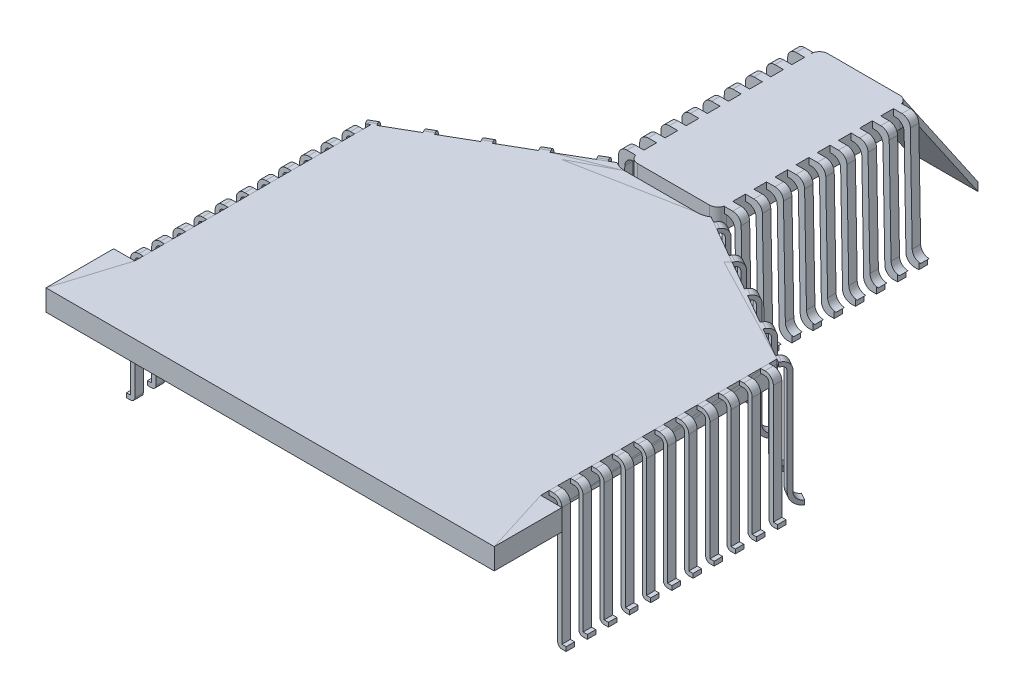
from build123d import *

# Parameters (mm, degrees)
SKETCH1_W             = 21
SKETCH1_H             = 45
BOSS_EXTRUDE1_DEPTH   = 5
FILLET1_R             = 2
BOSS_EXTRUDE2_DEPTH   = 1
LPATTERN1_COUNT       = 5
LPATTERN1_PITCH       = 5
LPATTERN1_COUNT_DIR2  = 5
LPATTERN1_PITCH_DIR2  = 5
MIRROR1_COPY_1_DEPTH  = 1
MIRROR1_COPY_2_DEPTH  = 1
MIRROR1_COPY_3_DEPTH  = 1
MIRROR1_COPY_4_DEPTH  = 1
MIRROR1_COPY_5_DEPTH  = 1
MIRROR1_COPY_6_DEPTH  = 1
MIRROR1_COPY_7_DEPTH  = 1
MIRROR1_COPY_8_DEPTH  = 1
MIRROR1_COPY_9_DEPTH  = 1
MIRROR1_COPY_10_DEPTH = 1
MIRROR1_COPY_11_DEPTH = 1
MIRROR1_COPY_12_DEPTH = 1
MIRROR1_COPY_13_DEPTH = 1
MIRROR1_COPY_14_DEPTH = 1
MIRROR1_COPY_15_DEPTH = 1
MIRROR1_COPY_16_DEPTH = 1
MIRROR1_COPY_17_DEPTH = 1
MIRROR1_COPY_18_DEPTH = 1
MIRROR1_COPY_19_DEPTH = 1
MIRROR1_COPY_20_DEPTH = 1
MIRROR1_COPY_21_DEPTH = 1
MIRROR1_COPY_22_DEPTH = 1
MIRROR1_COPY_23_DEPTH = 1
MIRROR1_COPY_24_DEPTH = 1
SKETCH4_W             = 17
SKETCH4_H             = 2
BOSS_EXTRUDE4_DEPTH   = 5
BOSS_EXTRUDE5_DEPTH   = 1
LPATTERN2_COUNT       = 5
LPATTERN2_PITCH       = 10
BOSS_EXTRUDE7_START   = 2
BOSS_EXTRUDE7_DEPTH   = 2
LPATTERN3_COUNT       = 11
LPATTERN3_PITCH       = 5


with BuildPart() as part:
    # Sketch1 → Boss-Extrude1 (new body)
    with BuildSketch(Plane(origin=(0, 0, 0), x_dir=(1, 0, 0), z_dir=(0, 1, 0))):
        Rectangle(SKETCH1_W, SKETCH1_H)
    extrude(amount=BOSS_EXTRUDE1_DEPTH)

    # Fillet1
    fillet1_edges = [part.edges().sort_by_distance(p)[0] for p in [
        (-10.5, 2.5, -22.5),
        (-10.5, 2.5, 22.5),
        (10.5, 2.5, -22.5),
        (10.5, 2.5, 22.5),
    ]]
    fillet(fillet1_edges, radius=FILLET1_R)

    # Sketch2 → Boss-Extrude2 (add, symmetric)
    with BuildSketch(Plane.XY):
        with BuildLine():
            Line((10.5, 3.5), (11.026542382, 3.5))
            ThreePointArc((11.026542382, 3.5), (12.428076219, 2.926780608), (13.026223683, 1.535702904))
            Line((13.026223683, 1.535702904), (13.464928856, -23.035702904))
            ThreePointArc((13.464928856, -23.035702904), (14.06307632, -24.426780608), (15.464610157, -25))
            Line((15.464610157, -25), (16.5, -25))
            Line((16.5, -25), (16.5, -23.5))
            Line((16.5, -23.5), (16.938067774, -23.5))
            ThreePointArc((16.938067774, -23.5), (15.536533937, -22.926780608), (14.938386474, -21.535702904))
            Line((14.938386474, -21.535702904), (14.4996813, 3.035702904))
            ThreePointArc((14.4996813, 3.035702904), (13.901533837, 4.426780608), (12.5, 5))
            Line((12.5, 5), (10.5, 5))
            Line((10.5, 5), (10.5, 3.5))
        make_face()
    boss_extrude2 = extrude(amount=BOSS_EXTRUDE2_DEPTH, both=True)

    # LPattern1: Boss-Extrude2 5 × 5
    with Locations(*[Vector(0, 0, -1) * (i * LPATTERN1_PITCH) + Vector(0, 0, 1) * (j * LPATTERN1_PITCH_DIR2) for i in range(LPATTERN1_COUNT) for j in range(LPATTERN1_COUNT_DIR2) if (i, j) != (0, 0)]):
        add(boss_extrude2)

    # Mirror1: Boss-Extrude2 across plane
    add(boss_extrude2.mirror(Plane(origin=(0, 0, 0), x_dir=(0, 0, 1), z_dir=(1, 0, 0))))

    # Mirror1 copy 1 sketch → Mirror1 copy 1 (add, symmetric)
    with BuildSketch(Plane(origin=(0, 0, 5), x_dir=(-1, 0, 0), z_dir=(0, 0, 1))):
        with BuildLine():
            Line((10.5, -3.5), (11.026542382, -3.5))
            ThreePointArc((11.026542382, -3.5), (12.428076219, -2.926780608), (13.026223683, -1.535702904))
            Line((13.026223683, -1.535702904), (13.464928856, 23.035702904))
            ThreePointArc((13.464928856, 23.035702904), (14.06307632, 24.426780608), (15.464610157, 25))
            Line((15.464610157, 25), (16.5, 25))
            Line((16.5, 25), (16.5, 23.5))
            Line((16.5, 23.5), (16.938067774, 23.5))
            ThreePointArc((16.938067774, 23.5), (15.536533937, 22.926780608), (14.938386474, 21.535702904))
            Line((14.938386474, 21.535702904), (14.4996813, -3.035702904))
            ThreePointArc((14.4996813, -3.035702904), (13.901533837, -4.426780608), (12.5, -5))
            Line((12.5, -5), (10.5, -5))
            Line((10.5, -5), (10.5, -3.5))
        make_face()
    extrude(amount=MIRROR1_COPY_1_DEPTH, both=True)

    # Mirror1 copy 2 sketch → Mirror1 copy 2 (add, symmetric)
    with BuildSketch(Plane(origin=(0, 0, 10), x_dir=(-1, 0, 0), z_dir=(0, 0, 1))):
        with BuildLine():
            Line((10.5, -3.5), (11.026542382, -3.5))
            ThreePointArc((11.026542382, -3.5), (12.428076219, -2.926780608), (13.026223683, -1.535702904))
            Line((13.026223683, -1.535702904), (13.464928856, 23.035702904))
            ThreePointArc((13.464928856, 23.035702904), (14.06307632, 24.426780608), (15.464610157, 25))
            Line((15.464610157, 25), (16.5, 25))
            Line((16.5, 25), (16.5, 23.5))
            Line((16.5, 23.5), (16.938067774, 23.5))
            ThreePointArc((16.938067774, 23.5), (15.536533937, 22.926780608), (14.938386474, 21.535702904))
            Line((14.938386474, 21.535702904), (14.4996813, -3.035702904))
            ThreePointArc((14.4996813, -3.035702904), (13.901533837, -4.426780608), (12.5, -5))
            Line((12.5, -5), (10.5, -5))
            Line((10.5, -5), (10.5, -3.5))
        make_face()
    extrude(amount=MIRROR1_COPY_2_DEPTH, both=True)

    # Mirror1 copy 3 sketch → Mirror1 copy 3 (add, symmetric)
    with BuildSketch(Plane(origin=(0, 0, 15), x_dir=(-1, 0, 0), z_dir=(0, 0, 1))):
        with BuildLine():
            Line((10.5, -3.5), (11.026542382, -3.5))
            ThreePointArc((11.026542382, -3.5), (12.428076219, -2.926780608), (13.026223683, -1.535702904))
            Line((13.026223683, -1.535702904), (13.464928856, 23.035702904))
            ThreePointArc((13.464928856, 23.035702904), (14.06307632, 24.426780608), (15.464610157, 25))
            Line((15.464610157, 25), (16.5, 25))
            Line((16.5, 25), (16.5, 23.5))
            Line((16.5, 23.5), (16.938067774, 23.5))
            ThreePointArc((16.938067774, 23.5), (15.536533937, 22.926780608), (14.938386474, 21.535702904))
            Line((14.938386474, 21.535702904), (14.4996813, -3.035702904))
            ThreePointArc((14.4996813, -3.035702904), (13.901533837, -4.426780608), (12.5, -5))
            Line((12.5, -5), (10.5, -5))
            Line((10.5, -5), (10.5, -3.5))
        make_face()
    extrude(amount=MIRROR1_COPY_3_DEPTH, both=True)

    # Mirror1 copy 4 sketch → Mirror1 copy 4 (add, symmetric)
    with BuildSketch(Plane(origin=(0, 0, 20), x_dir=(-1, 0, 0), z_dir=(0, 0, 1))):
        with BuildLine():
            Line((10.5, -3.5), (11.026542382, -3.5))
            ThreePointArc((11.026542382, -3.5), (12.428076219, -2.926780608), (13.026223683, -1.535702904))
            Line((13.026223683, -1.535702904), (13.464928856, 23.035702904))
            ThreePointArc((13.464928856, 23.035702904), (14.06307632, 24.426780608), (15.464610157, 25))
            Line((15.464610157, 25), (16.5, 25))
            Line((16.5, 25), (16.5, 23.5))
            Line((16.5, 23.5), (16.938067774, 23.5))
            ThreePointArc((16.938067774, 23.5), (15.536533937, 22.926780608), (14.938386474, 21.535702904))
            Line((14.938386474, 21.535702904), (14.4996813, -3.035702904))
            ThreePointArc((14.4996813, -3.035702904), (13.901533837, -4.426780608), (12.5, -5))
            Line((12.5, -5), (10.5, -5))
            Line((10.5, -5), (10.5, -3.5))
        make_face()
    extrude(amount=MIRROR1_COPY_4_DEPTH, both=True)

    # Mirror1 copy 5 sketch → Mirror1 copy 5 (add, symmetric)
    with BuildSketch(Plane(origin=(0, 0, -5), x_dir=(-1, 0, 0), z_dir=(0, 0, 1))):
        with BuildLine():
            Line((10.5, -3.5), (11.026542382, -3.5))
            ThreePointArc((11.026542382, -3.5), (12.428076219, -2.926780608), (13.026223683, -1.535702904))
            Line((13.026223683, -1.535702904), (13.464928856, 23.035702904))
            ThreePointArc((13.464928856, 23.035702904), (14.06307632, 24.426780608), (15.464610157, 25))
            Line((15.464610157, 25), (16.5, 25))
            Line((16.5, 25), (16.5, 23.5))
            Line((16.5, 23.5), (16.938067774, 23.5))
            ThreePointArc((16.938067774, 23.5), (15.536533937, 22.926780608), (14.938386474, 21.535702904))
            Line((14.938386474, 21.535702904), (14.4996813, -3.035702904))
            ThreePointArc((14.4996813, -3.035702904), (13.901533837, -4.426780608), (12.5, -5))
            Line((12.5, -5), (10.5, -5))
            Line((10.5, -5), (10.5, -3.5))
        make_face()
    extrude(amount=MIRROR1_COPY_5_DEPTH, both=True)

    # Mirror1 copy 6 sketch → Mirror1 copy 6 (add, symmetric)
    with BuildSketch(Plane(origin=(0, 0, 0), x_dir=(-1, 0, 0), z_dir=(0, 0, 1))):
        with BuildLine():
            Line((10.5, -3.5), (11.026542382, -3.5))
            ThreePointArc((11.026542382, -3.5), (12.428076219, -2.926780608), (13.026223683, -1.535702904))
            Line((13.026223683, -1.535702904), (13.464928856, 23.035702904))
            ThreePointArc((13.464928856, 23.035702904), (14.06307632, 24.426780608), (15.464610157, 25))
            Line((15.464610157, 25), (16.5, 25))
            Line((16.5, 25), (16.5, 23.5))
            Line((16.5, 23.5), (16.938067774, 23.5))
            ThreePointArc((16.938067774, 23.5), (15.536533937, 22.926780608), (14.938386474, 21.535702904))
            Line((14.938386474, 21.535702904), (14.4996813, -3.035702904))
            ThreePointArc((14.4996813, -3.035702904), (13.901533837, -4.426780608), (12.5, -5))
            Line((12.5, -5), (10.5, -5))
            Line((10.5, -5), (10.5, -3.5))
        make_face()
    extrude(amount=MIRROR1_COPY_6_DEPTH, both=True)

    # Mirror1 copy 7 sketch → Mirror1 copy 7 (add, symmetric)
    with BuildSketch(Plane(origin=(0, 0, 5), x_dir=(-1, 0, 0), z_dir=(0, 0, 1))):
        with BuildLine():
            Line((10.5, -3.5), (11.026542382, -3.5))
            ThreePointArc((11.026542382, -3.5), (12.428076219, -2.926780608), (13.026223683, -1.535702904))
            Line((13.026223683, -1.535702904), (13.464928856, 23.035702904))
            ThreePointArc((13.464928856, 23.035702904), (14.06307632, 24.426780608), (15.464610157, 25))
            Line((15.464610157, 25), (16.5, 25))
            Line((16.5, 25), (16.5, 23.5))
            Line((16.5, 23.5), (16.938067774, 23.5))
            ThreePointArc((16.938067774, 23.5), (15.536533937, 22.926780608), (14.938386474, 21.535702904))
            Line((14.938386474, 21.535702904), (14.4996813, -3.035702904))
            ThreePointArc((14.4996813, -3.035702904), (13.901533837, -4.426780608), (12.5, -5))
            Line((12.5, -5), (10.5, -5))
            Line((10.5, -5), (10.5, -3.5))
        make_face()
    extrude(amount=MIRROR1_COPY_7_DEPTH, both=True)

    # Mirror1 copy 8 sketch → Mirror1 copy 8 (add, symmetric)
    with BuildSketch(Plane(origin=(0, 0, 10), x_dir=(-1, 0, 0), z_dir=(0, 0, 1))):
        with BuildLine():
            Line((10.5, -3.5), (11.026542382, -3.5))
            ThreePointArc((11.026542382, -3.5), (12.428076219, -2.926780608), (13.026223683, -1.535702904))
            Line((13.026223683, -1.535702904), (13.464928856, 23.035702904))
            ThreePointArc((13.464928856, 23.035702904), (14.06307632, 24.426780608), (15.464610157, 25))
            Line((15.464610157, 25), (16.5, 25))
            Line((16.5, 25), (16.5, 23.5))
            Line((16.5, 23.5), (16.938067774, 23.5))
            ThreePointArc((16.938067774, 23.5), (15.536533937, 22.926780608), (14.938386474, 21.535702904))
            Line((14.938386474, 21.535702904), (14.4996813, -3.035702904))
            ThreePointArc((14.4996813, -3.035702904), (13.901533837, -4.426780608), (12.5, -5))
            Line((12.5, -5), (10.5, -5))
            Line((10.5, -5), (10.5, -3.5))
        make_face()
    extrude(amount=MIRROR1_COPY_8_DEPTH, both=True)

    # Mirror1 copy 9 sketch → Mirror1 copy 9 (add, symmetric)
    with BuildSketch(Plane(origin=(0, 0, 15), x_dir=(-1, 0, 0), z_dir=(0, 0, 1))):
        with BuildLine():
            Line((10.5, -3.5), (11.026542382, -3.5))
            ThreePointArc((11.026542382, -3.5), (12.428076219, -2.926780608), (13.026223683, -1.535702904))
            Line((13.026223683, -1.535702904), (13.464928856, 23.035702904))
            ThreePointArc((13.464928856, 23.035702904), (14.06307632, 24.426780608), (15.464610157, 25))
            Line((15.464610157, 25), (16.5, 25))
            Line((16.5, 25), (16.5, 23.5))
            Line((16.5, 23.5), (16.938067774, 23.5))
            ThreePointArc((16.938067774, 23.5), (15.536533937, 22.926780608), (14.938386474, 21.535702904))
            Line((14.938386474, 21.535702904), (14.4996813, -3.035702904))
            ThreePointArc((14.4996813, -3.035702904), (13.901533837, -4.426780608), (12.5, -5))
            Line((12.5, -5), (10.5, -5))
            Line((10.5, -5), (10.5, -3.5))
        make_face()
    extrude(amount=MIRROR1_COPY_9_DEPTH, both=True)

    # Mirror1 copy 10 sketch → Mirror1 copy 10 (add, symmetric)
    with BuildSketch(Plane(origin=(0, 0, -10), x_dir=(-1, 0, 0), z_dir=(0, 0, 1))):
        with BuildLine():
            Line((10.5, -3.5), (11.026542382, -3.5))
            ThreePointArc((11.026542382, -3.5), (12.428076219, -2.926780608), (13.026223683, -1.535702904))
            Line((13.026223683, -1.535702904), (13.464928856, 23.035702904))
            ThreePointArc((13.464928856, 23.035702904), (14.06307632, 24.426780608), (15.464610157, 25))
            Line((15.464610157, 25), (16.5, 25))
            Line((16.5, 25), (16.5, 23.5))
            Line((16.5, 23.5), (16.938067774, 23.5))
            ThreePointArc((16.938067774, 23.5), (15.536533937, 22.926780608), (14.938386474, 21.535702904))
            Line((14.938386474, 21.535702904), (14.4996813, -3.035702904))
            ThreePointArc((14.4996813, -3.035702904), (13.901533837, -4.426780608), (12.5, -5))
            Line((12.5, -5), (10.5, -5))
            Line((10.5, -5), (10.5, -3.5))
        make_face()
    extrude(amount=MIRROR1_COPY_10_DEPTH, both=True)

    # Mirror1 copy 11 sketch → Mirror1 copy 11 (add, symmetric)
    with BuildSketch(Plane(origin=(0, 0, -5), x_dir=(-1, 0, 0), z_dir=(0, 0, 1))):
        with BuildLine():
            Line((10.5, -3.5), (11.026542382, -3.5))
            ThreePointArc((11.026542382, -3.5), (12.428076219, -2.926780608), (13.026223683, -1.535702904))
            Line((13.026223683, -1.535702904), (13.464928856, 23.035702904))
            ThreePointArc((13.464928856, 23.035702904), (14.06307632, 24.426780608), (15.464610157, 25))
            Line((15.464610157, 25), (16.5, 25))
            Line((16.5, 25), (16.5, 23.5))
            Line((16.5, 23.5), (16.938067774, 23.5))
            ThreePointArc((16.938067774, 23.5), (15.536533937, 22.926780608), (14.938386474, 21.535702904))
            Line((14.938386474, 21.535702904), (14.4996813, -3.035702904))
            ThreePointArc((14.4996813, -3.035702904), (13.901533837, -4.426780608), (12.5, -5))
            Line((12.5, -5), (10.5, -5))
            Line((10.5, -5), (10.5, -3.5))
        make_face()
    extrude(amount=MIRROR1_COPY_11_DEPTH, both=True)

    # Mirror1 copy 12 sketch → Mirror1 copy 12 (add, symmetric)
    with BuildSketch(Plane(origin=(0, 0, 0), x_dir=(-1, 0, 0), z_dir=(0, 0, 1))):
        with BuildLine():
            Line((10.5, -3.5), (11.026542382, -3.5))
            ThreePointArc((11.026542382, -3.5), (12.428076219, -2.926780608), (13.026223683, -1.535702904))
            Line((13.026223683, -1.535702904), (13.464928856, 23.035702904))
            ThreePointArc((13.464928856, 23.035702904), (14.06307632, 24.426780608), (15.464610157, 25))
            Line((15.464610157, 25), (16.5, 25))
            Line((16.5, 25), (16.5, 23.5))
            Line((16.5, 23.5), (16.938067774, 23.5))
            ThreePointArc((16.938067774, 23.5), (15.536533937, 22.926780608), (14.938386474, 21.535702904))
            Line((14.938386474, 21.535702904), (14.4996813, -3.035702904))
            ThreePointArc((14.4996813, -3.035702904), (13.901533837, -4.426780608), (12.5, -5))
            Line((12.5, -5), (10.5, -5))
            Line((10.5, -5), (10.5, -3.5))
        make_face()
    extrude(amount=MIRROR1_COPY_12_DEPTH, both=True)

    # Mirror1 copy 13 sketch → Mirror1 copy 13 (add, symmetric)
    with BuildSketch(Plane(origin=(0, 0, 5), x_dir=(-1, 0, 0), z_dir=(0, 0, 1))):
        with BuildLine():
            Line((10.5, -3.5), (11.026542382, -3.5))
            ThreePointArc((11.026542382, -3.5), (12.428076219, -2.926780608), (13.026223683, -1.535702904))
            Line((13.026223683, -1.535702904), (13.464928856, 23.035702904))
            ThreePointArc((13.464928856, 23.035702904), (14.06307632, 24.426780608), (15.464610157, 25))
            Line((15.464610157, 25), (16.5, 25))
            Line((16.5, 25), (16.5, 23.5))
            Line((16.5, 23.5), (16.938067774, 23.5))
            ThreePointArc((16.938067774, 23.5), (15.536533937, 22.926780608), (14.938386474, 21.535702904))
            Line((14.938386474, 21.535702904), (14.4996813, -3.035702904))
            ThreePointArc((14.4996813, -3.035702904), (13.901533837, -4.426780608), (12.5, -5))
            Line((12.5, -5), (10.5, -5))
            Line((10.5, -5), (10.5, -3.5))
        make_face()
    extrude(amount=MIRROR1_COPY_13_DEPTH, both=True)

    # Mirror1 copy 14 sketch → Mirror1 copy 14 (add, symmetric)
    with BuildSketch(Plane(origin=(0, 0, 10), x_dir=(-1, 0, 0), z_dir=(0, 0, 1))):
        with BuildLine():
            Line((10.5, -3.5), (11.026542382, -3.5))
            ThreePointArc((11.026542382, -3.5), (12.428076219, -2.926780608), (13.026223683, -1.535702904))
            Line((13.026223683, -1.535702904), (13.464928856, 23.035702904))
            ThreePointArc((13.464928856, 23.035702904), (14.06307632, 24.426780608), (15.464610157, 25))
            Line((15.464610157, 25), (16.5, 25))
            Line((16.5, 25), (16.5, 23.5))
            Line((16.5, 23.5), (16.938067774, 23.5))
            ThreePointArc((16.938067774, 23.5), (15.536533937, 22.926780608), (14.938386474, 21.535702904))
            Line((14.938386474, 21.535702904), (14.4996813, -3.035702904))
            ThreePointArc((14.4996813, -3.035702904), (13.901533837, -4.426780608), (12.5, -5))
            Line((12.5, -5), (10.5, -5))
            Line((10.5, -5), (10.5, -3.5))
        make_face()
    extrude(amount=MIRROR1_COPY_14_DEPTH, both=True)

    # Mirror1 copy 15 sketch → Mirror1 copy 15 (add, symmetric)
    with BuildSketch(Plane(origin=(0, 0, -15), x_dir=(-1, 0, 0), z_dir=(0, 0, 1))):
        with BuildLine():
            Line((10.5, -3.5), (11.026542382, -3.5))
            ThreePointArc((11.026542382, -3.5), (12.428076219, -2.926780608), (13.026223683, -1.535702904))
            Line((13.026223683, -1.535702904), (13.464928856, 23.035702904))
            ThreePointArc((13.464928856, 23.035702904), (14.06307632, 24.426780608), (15.464610157, 25))
            Line((15.464610157, 25), (16.5, 25))
            Line((16.5, 25), (16.5, 23.5))
            Line((16.5, 23.5), (16.938067774, 23.5))
            ThreePointArc((16.938067774, 23.5), (15.536533937, 22.926780608), (14.938386474, 21.535702904))
            Line((14.938386474, 21.535702904), (14.4996813, -3.035702904))
            ThreePointArc((14.4996813, -3.035702904), (13.901533837, -4.426780608), (12.5, -5))
            Line((12.5, -5), (10.5, -5))
            Line((10.5, -5), (10.5, -3.5))
        make_face()
    extrude(amount=MIRROR1_COPY_15_DEPTH, both=True)

    # Mirror1 copy 16 sketch → Mirror1 copy 16 (add, symmetric)
    with BuildSketch(Plane(origin=(0, 0, -10), x_dir=(-1, 0, 0), z_dir=(0, 0, 1))):
        with BuildLine():
            Line((10.5, -3.5), (11.026542382, -3.5))
            ThreePointArc((11.026542382, -3.5), (12.428076219, -2.926780608), (13.026223683, -1.535702904))
            Line((13.026223683, -1.535702904), (13.464928856, 23.035702904))
            ThreePointArc((13.464928856, 23.035702904), (14.06307632, 24.426780608), (15.464610157, 25))
            Line((15.464610157, 25), (16.5, 25))
            Line((16.5, 25), (16.5, 23.5))
            Line((16.5, 23.5), (16.938067774, 23.5))
            ThreePointArc((16.938067774, 23.5), (15.536533937, 22.926780608), (14.938386474, 21.535702904))
            Line((14.938386474, 21.535702904), (14.4996813, -3.035702904))
            ThreePointArc((14.4996813, -3.035702904), (13.901533837, -4.426780608), (12.5, -5))
            Line((12.5, -5), (10.5, -5))
            Line((10.5, -5), (10.5, -3.5))
        make_face()
    extrude(amount=MIRROR1_COPY_16_DEPTH, both=True)

    # Mirror1 copy 17 sketch → Mirror1 copy 17 (add, symmetric)
    with BuildSketch(Plane(origin=(0, 0, -5), x_dir=(-1, 0, 0), z_dir=(0, 0, 1))):
        with BuildLine():
            Line((10.5, -3.5), (11.026542382, -3.5))
            ThreePointArc((11.026542382, -3.5), (12.428076219, -2.926780608), (13.026223683, -1.535702904))
            Line((13.026223683, -1.535702904), (13.464928856, 23.035702904))
            ThreePointArc((13.464928856, 23.035702904), (14.06307632, 24.426780608), (15.464610157, 25))
            Line((15.464610157, 25), (16.5, 25))
            Line((16.5, 25), (16.5, 23.5))
            Line((16.5, 23.5), (16.938067774, 23.5))
            ThreePointArc((16.938067774, 23.5), (15.536533937, 22.926780608), (14.938386474, 21.535702904))
            Line((14.938386474, 21.535702904), (14.4996813, -3.035702904))
            ThreePointArc((14.4996813, -3.035702904), (13.901533837, -4.426780608), (12.5, -5))
            Line((12.5, -5), (10.5, -5))
            Line((10.5, -5), (10.5, -3.5))
        make_face()
    extrude(amount=MIRROR1_COPY_17_DEPTH, both=True)

    # Mirror1 copy 18 sketch → Mirror1 copy 18 (add, symmetric)
    with BuildSketch(Plane(origin=(0, 0, 0), x_dir=(-1, 0, 0), z_dir=(0, 0, 1))):
        with BuildLine():
            Line((10.5, -3.5), (11.026542382, -3.5))
            ThreePointArc((11.026542382, -3.5), (12.428076219, -2.926780608), (13.026223683, -1.535702904))
            Line((13.026223683, -1.535702904), (13.464928856, 23.035702904))
            ThreePointArc((13.464928856, 23.035702904), (14.06307632, 24.426780608), (15.464610157, 25))
            Line((15.464610157, 25), (16.5, 25))
            Line((16.5, 25), (16.5, 23.5))
            Line((16.5, 23.5), (16.938067774, 23.5))
            ThreePointArc((16.938067774, 23.5), (15.536533937, 22.926780608), (14.938386474, 21.535702904))
            Line((14.938386474, 21.535702904), (14.4996813, -3.035702904))
            ThreePointArc((14.4996813, -3.035702904), (13.901533837, -4.426780608), (12.5, -5))
            Line((12.5, -5), (10.5, -5))
            Line((10.5, -5), (10.5, -3.5))
        make_face()
    extrude(amount=MIRROR1_COPY_18_DEPTH, both=True)

    # Mirror1 copy 19 sketch → Mirror1 copy 19 (add, symmetric)
    with BuildSketch(Plane(origin=(0, 0, 5), x_dir=(-1, 0, 0), z_dir=(0, 0, 1))):
        with BuildLine():
            Line((10.5, -3.5), (11.026542382, -3.5))
            ThreePointArc((11.026542382, -3.5), (12.428076219, -2.926780608), (13.026223683, -1.535702904))
            Line((13.026223683, -1.535702904), (13.464928856, 23.035702904))
            ThreePointArc((13.464928856, 23.035702904), (14.06307632, 24.426780608), (15.464610157, 25))
            Line((15.464610157, 25), (16.5, 25))
            Line((16.5, 25), (16.5, 23.5))
            Line((16.5, 23.5), (16.938067774, 23.5))
            ThreePointArc((16.938067774, 23.5), (15.536533937, 22.926780608), (14.938386474, 21.535702904))
            Line((14.938386474, 21.535702904), (14.4996813, -3.035702904))
            ThreePointArc((14.4996813, -3.035702904), (13.901533837, -4.426780608), (12.5, -5))
            Line((12.5, -5), (10.5, -5))
            Line((10.5, -5), (10.5, -3.5))
        make_face()
    extrude(amount=MIRROR1_COPY_19_DEPTH, both=True)

    # Mirror1 copy 20 sketch → Mirror1 copy 20 (add, symmetric)
    with BuildSketch(Plane(origin=(0, 0, -20), x_dir=(-1, 0, 0), z_dir=(0, 0, 1))):
        with BuildLine():
            Line((10.5, -3.5), (11.026542382, -3.5))
            ThreePointArc((11.026542382, -3.5), (12.428076219, -2.926780608), (13.026223683, -1.535702904))
            Line((13.026223683, -1.535702904), (13.464928856, 23.035702904))
            ThreePointArc((13.464928856, 23.035702904), (14.06307632, 24.426780608), (15.464610157, 25))
            Line((15.464610157, 25), (16.5, 25))
            Line((16.5, 25), (16.5, 23.5))
            Line((16.5, 23.5), (16.938067774, 23.5))
            ThreePointArc((16.938067774, 23.5), (15.536533937, 22.926780608), (14.938386474, 21.535702904))
            Line((14.938386474, 21.535702904), (14.4996813, -3.035702904))
            ThreePointArc((14.4996813, -3.035702904), (13.901533837, -4.426780608), (12.5, -5))
            Line((12.5, -5), (10.5, -5))
            Line((10.5, -5), (10.5, -3.5))
        make_face()
    extrude(amount=MIRROR1_COPY_20_DEPTH, both=True)

    # Mirror1 copy 21 sketch → Mirror1 copy 21 (add, symmetric)
    with BuildSketch(Plane(origin=(0, 0, -15), x_dir=(-1, 0, 0), z_dir=(0, 0, 1))):
        with BuildLine():
            Line((10.5, -3.5), (11.026542382, -3.5))
            ThreePointArc((11.026542382, -3.5), (12.428076219, -2.926780608), (13.026223683, -1.535702904))
            Line((13.026223683, -1.535702904), (13.464928856, 23.035702904))
            ThreePointArc((13.464928856, 23.035702904), (14.06307632, 24.426780608), (15.464610157, 25))
            Line((15.464610157, 25), (16.5, 25))
            Line((16.5, 25), (16.5, 23.5))
            Line((16.5, 23.5), (16.938067774, 23.5))
            ThreePointArc((16.938067774, 23.5), (15.536533937, 22.926780608), (14.938386474, 21.535702904))
            Line((14.938386474, 21.535702904), (14.4996813, -3.035702904))
            ThreePointArc((14.4996813, -3.035702904), (13.901533837, -4.426780608), (12.5, -5))
            Line((12.5, -5), (10.5, -5))
            Line((10.5, -5), (10.5, -3.5))
        make_face()
    extrude(amount=MIRROR1_COPY_21_DEPTH, both=True)

    # Mirror1 copy 22 sketch → Mirror1 copy 22 (add, symmetric)
    with BuildSketch(Plane(origin=(0, 0, -10), x_dir=(-1, 0, 0), z_dir=(0, 0, 1))):
        with BuildLine():
            Line((10.5, -3.5), (11.026542382, -3.5))
            ThreePointArc((11.026542382, -3.5), (12.428076219, -2.926780608), (13.026223683, -1.535702904))
            Line((13.026223683, -1.535702904), (13.464928856, 23.035702904))
            ThreePointArc((13.464928856, 23.035702904), (14.06307632, 24.426780608), (15.464610157, 25))
            Line((15.464610157, 25), (16.5, 25))
            Line((16.5, 25), (16.5, 23.5))
            Line((16.5, 23.5), (16.938067774, 23.5))
            ThreePointArc((16.938067774, 23.5), (15.536533937, 22.926780608), (14.938386474, 21.535702904))
            Line((14.938386474, 21.535702904), (14.4996813, -3.035702904))
            ThreePointArc((14.4996813, -3.035702904), (13.901533837, -4.426780608), (12.5, -5))
            Line((12.5, -5), (10.5, -5))
            Line((10.5, -5), (10.5, -3.5))
        make_face()
    extrude(amount=MIRROR1_COPY_22_DEPTH, both=True)

    # Mirror1 copy 23 sketch → Mirror1 copy 23 (add, symmetric)
    with BuildSketch(Plane(origin=(0, 0, -5), x_dir=(-1, 0, 0), z_dir=(0, 0, 1))):
        with BuildLine():
            Line((10.5, -3.5), (11.026542382, -3.5))
            ThreePointArc((11.026542382, -3.5), (12.428076219, -2.926780608), (13.026223683, -1.535702904))
            Line((13.026223683, -1.535702904), (13.464928856, 23.035702904))
            ThreePointArc((13.464928856, 23.035702904), (14.06307632, 24.426780608), (15.464610157, 25))
            Line((15.464610157, 25), (16.5, 25))
            Line((16.5, 25), (16.5, 23.5))
            Line((16.5, 23.5), (16.938067774, 23.5))
            ThreePointArc((16.938067774, 23.5), (15.536533937, 22.926780608), (14.938386474, 21.535702904))
            Line((14.938386474, 21.535702904), (14.4996813, -3.035702904))
            ThreePointArc((14.4996813, -3.035702904), (13.901533837, -4.426780608), (12.5, -5))
            Line((12.5, -5), (10.5, -5))
            Line((10.5, -5), (10.5, -3.5))
        make_face()
    extrude(amount=MIRROR1_COPY_23_DEPTH, both=True)

    # Mirror1 copy 24 sketch → Mirror1 copy 24 (add, symmetric)
    with BuildSketch(Plane(origin=(0, 0, 0), x_dir=(-1, 0, 0), z_dir=(0, 0, 1))):
        with BuildLine():
            Line((10.5, -3.5), (11.026542382, -3.5))
            ThreePointArc((11.026542382, -3.5), (12.428076219, -2.926780608), (13.026223683, -1.535702904))
            Line((13.026223683, -1.535702904), (13.464928856, 23.035702904))
            ThreePointArc((13.464928856, 23.035702904), (14.06307632, 24.426780608), (15.464610157, 25))
            Line((15.464610157, 25), (16.5, 25))
            Line((16.5, 25), (16.5, 23.5))
            Line((16.5, 23.5), (16.938067774, 23.5))
            ThreePointArc((16.938067774, 23.5), (15.536533937, 22.926780608), (14.938386474, 21.535702904))
            Line((14.938386474, 21.535702904), (14.4996813, -3.035702904))
            ThreePointArc((14.4996813, -3.035702904), (13.901533837, -4.426780608), (12.5, -5))
            Line((12.5, -5), (10.5, -5))
            Line((10.5, -5), (10.5, -3.5))
        make_face()
    extrude(amount=MIRROR1_COPY_24_DEPTH, both=True)

    # Sweep1: sweep along a path in Sketch3
    with BuildLine(Plane(origin=(0, 0, 0), x_dir=(0, 0, -1), z_dir=(1, 0, 0))) as sweep1_path:
        Line((22.5, 5), (41, -22))
    # Sketch4 → Sweep1 (sweep)
    with BuildSketch(Plane(origin=(0, 0, -22.5), x_dir=(-1, 0, 0), z_dir=(0, 0, -1))):
        with Locations((0, 4)):
            Rectangle(SKETCH4_W, SKETCH4_H)
    sweep(path=sweep1_path.line)


with BuildPart() as body_2:
    # Sketch5_2 → Boss-Extrude4 (new body)
    with BuildSketch(Plane(origin=(0, 5, 0), x_dir=(1, 0, 0), z_dir=(0, 1, 0))):
        with BuildLine():
            ThreePointArc((-8.5, -25.5), (-9.873003156, -25.307791835), (-11.140445346, -24.745944933))
            Line((-11.140445346, -24.745944933), (-48, -46.026818735))
            Line((-48, -46.026818735), (-48, -101.889924217))
            Line((-48, -101.889924217), (-53, -101.889924217))
            Line((-53, -101.889924217), (-53, -117.889924217))
            Line((-53, -117.889924217), (53, -117.889924217))
            Line((53, -117.889924217), (53, -101.889924217))
            Line((53, -101.889924217), (48, -101.889924217))
            Line((48, -101.889924217), (48, -46.026818735))
            Line((48, -46.026818735), (11.140445346, -24.745944933))
            ThreePointArc((11.140445346, -24.745944933), (9.873003156, -25.307791835), (8.5, -25.5))
            Line((8.5, -25.5), (-8.5, -25.5))
        make_face()
    extrude(amount=-BOSS_EXTRUDE4_DEPTH)

    # Sketch8 → Boss-Extrude5 (add, symmetric)
    with BuildSketch(Plane(origin=(55.93019714, 0, 32.291314375), x_dir=(0, 1, 0), z_dir=(-0.8660254037844398, 0, -0.49999999999999795))):
        with BuildLine():
            Line((5, -15.86039428), (5, -15.36039428))
            ThreePointArc((5, -15.36039428), (4.414213562, -13.946180717), (3, -13.36039428))
            Line((3, -13.36039428), (-22, -13.36039428))
            ThreePointArc((-22, -13.36039428), (-23.414213562, -12.774607842), (-24, -11.36039428))
            Line((-24, -11.36039428), (-25, -11.36039428))
            ThreePointArc((-25, -11.36039428), (-24.121320344, -13.481714623), (-22, -14.36039428))
            Line((-22, -14.36039428), (3, -14.36039428))
            ThreePointArc((3, -14.36039428), (3.707106781, -14.653287499), (4, -15.36039428))
            Line((4, -15.36039428), (4, -15.86039428))
            Line((4, -15.86039428), (5, -15.86039428))
        make_face()
    boss_extrude5 = extrude(amount=BOSS_EXTRUDE5_DEPTH, both=True)

    # LPattern2: Boss-Extrude5 ×5
    with Locations(*[Vector(-0.8660254037844398, 0, -0.49999999999999795) * (i * LPATTERN2_PITCH) for i in range(1, LPATTERN2_COUNT)]):
        add(boss_extrude5)


with BuildPart() as body_3:
    # Sketch9 → Boss-Extrude7 (new body)
    with BuildSketch(Plane.YX.offset(-101.889924217).offset(BOSS_EXTRUDE7_START)):
        with BuildLine():
            Line((4, 48), (4, 49))
            ThreePointArc((4, 49), (3.707106781, 49.707106781), (3, 50))
            Line((3, 50), (-25, 50))
            ThreePointArc((-25, 50), (-25.707106781, 50.292893219), (-26, 51))
            Line((-26, 51), (-26, 52))
            Line((-26, 52), (-25, 52))
            Line((-25, 52), (-25, 51))
            Line((-25, 51), (3, 51))
            ThreePointArc((3, 51), (4.414213562, 50.414213562), (5, 49))
            Line((5, 49), (5, 48))
            Line((5, 48), (4, 48))
        make_face()
    boss_extrude7 = extrude(amount=BOSS_EXTRUDE7_DEPTH)


with BuildPart() as lpattern3_1:
    # LPattern3: pattern copy
    add(boss_extrude7.moved(Location(Vector(0, 0, -1) * (1 * LPATTERN3_PITCH))))


with BuildPart() as lpattern3_2:
    # LPattern3: pattern copy
    add(boss_extrude7.moved(Location(Vector(0, 0, -1) * (2 * LPATTERN3_PITCH))))


with BuildPart() as lpattern3_3:
    # LPattern3: pattern copy
    add(boss_extrude7.moved(Location(Vector(0, 0, -1) * (3 * LPATTERN3_PITCH))))


with BuildPart() as lpattern3_4:
    # LPattern3: pattern copy
    add(boss_extrude7.moved(Location(Vector(0, 0, -1) * (4 * LPATTERN3_PITCH))))


with BuildPart() as lpattern3_5:
    # LPattern3: pattern copy
    add(boss_extrude7.moved(Location(Vector(0, 0, -1) * (5 * LPATTERN3_PITCH))))


with BuildPart() as lpattern3_6:
    # LPattern3: pattern copy
    add(boss_extrude7.moved(Location(Vector(0, 0, -1) * (6 * LPATTERN3_PITCH))))


with BuildPart() as lpattern3_7:
    # LPattern3: pattern copy
    add(boss_extrude7.moved(Location(Vector(0, 0, -1) * (7 * LPATTERN3_PITCH))))


with BuildPart() as lpattern3_8:
    # LPattern3: pattern copy
    add(boss_extrude7.moved(Location(Vector(0, 0, -1) * (8 * LPATTERN3_PITCH))))


with BuildPart() as lpattern3_9:
    # LPattern3: pattern copy
    add(boss_extrude7.moved(Location(Vector(0, 0, -1) * (9 * LPATTERN3_PITCH))))


with BuildPart() as lpattern3_10:
    # LPattern3: pattern copy
    add(boss_extrude7.moved(Location(Vector(0, 0, -1) * (10 * LPATTERN3_PITCH))))


with BuildPart() as body_14:
    # Mirror6: mirrored copy
    add(body_3.part.mirror(Plane(origin=(0, 0, 0), x_dir=(0, 0, 1), z_dir=(1, 0, 0))))


with BuildPart() as body_15:
    # Mirror6 2: mirrored copy
    add(lpattern3_1.part.mirror(Plane(origin=(0, 0, 0), x_dir=(0, 0, 1), z_dir=(1, 0, 0))))


with BuildPart() as body_16:
    # Mirror6 3: mirrored copy
    add(lpattern3_2.part.mirror(Plane(origin=(0, 0, 0), x_dir=(0, 0, 1), z_dir=(1, 0, 0))))


with BuildPart() as body_17:
    # Mirror6 4: mirrored copy
    add(lpattern3_3.part.mirror(Plane(origin=(0, 0, 0), x_dir=(0, 0, 1), z_dir=(1, 0, 0))))


with BuildPart() as body_18:
    # Mirror6 5: mirrored copy
    add(lpattern3_4.part.mirror(Plane(origin=(0, 0, 0), x_dir=(0, 0, 1), z_dir=(1, 0, 0))))


with BuildPart() as body_19:
    # Mirror6 6: mirrored copy
    add(lpattern3_5.part.mirror(Plane(origin=(0, 0, 0), x_dir=(0, 0, 1), z_dir=(1, 0, 0))))


with BuildPart() as body_20:
    # Mirror6 7: mirrored copy
    add(lpattern3_6.part.mirror(Plane(origin=(0, 0, 0), x_dir=(0, 0, 1), z_dir=(1, 0, 0))))


with BuildPart() as body_21:
    # Mirror6 8: mirrored copy
    add(lpattern3_7.part.mirror(Plane(origin=(0, 0, 0), x_dir=(0, 0, 1), z_dir=(1, 0, 0))))


with BuildPart() as body_22:
    # Mirror6 9: mirrored copy
    add(lpattern3_8.part.mirror(Plane(origin=(0, 0, 0), x_dir=(0, 0, 1), z_dir=(1, 0, 0))))


with BuildPart() as body_23:
    # Mirror6 10: mirrored copy
    add(lpattern3_9.part.mirror(Plane(origin=(0, 0, 0), x_dir=(0, 0, 1), z_dir=(1, 0, 0))))


with BuildPart() as body_24:
    # Mirror6 11: mirrored copy
    add(lpattern3_10.part.mirror(Plane(origin=(0, 0, 0), x_dir=(0, 0, 1), z_dir=(1, 0, 0))))


with BuildPart() as body_25:
    # Mirror6 12: mirrored copy
    add(body_2.part.mirror(Plane(origin=(0, 0, 0), x_dir=(0, 0, 1), z_dir=(1, 0, 0))))


solid = Compound([part.part, body_2.part, body_3.part, lpattern3_1.part, lpattern3_2.part, lpattern3_3.part, lpattern3_4.part, lpattern3_5.part, lpattern3_6.part, lpattern3_7.part, lpattern3_8.part, lpattern3_9.part, lpattern3_10.part, body_14.part, body_15.part, body_16.part, body_17.part, body_18.part, body_19.part, body_20.part, body_21.part, body_22.part, body_23.part, body_24.part, body_25.part])
